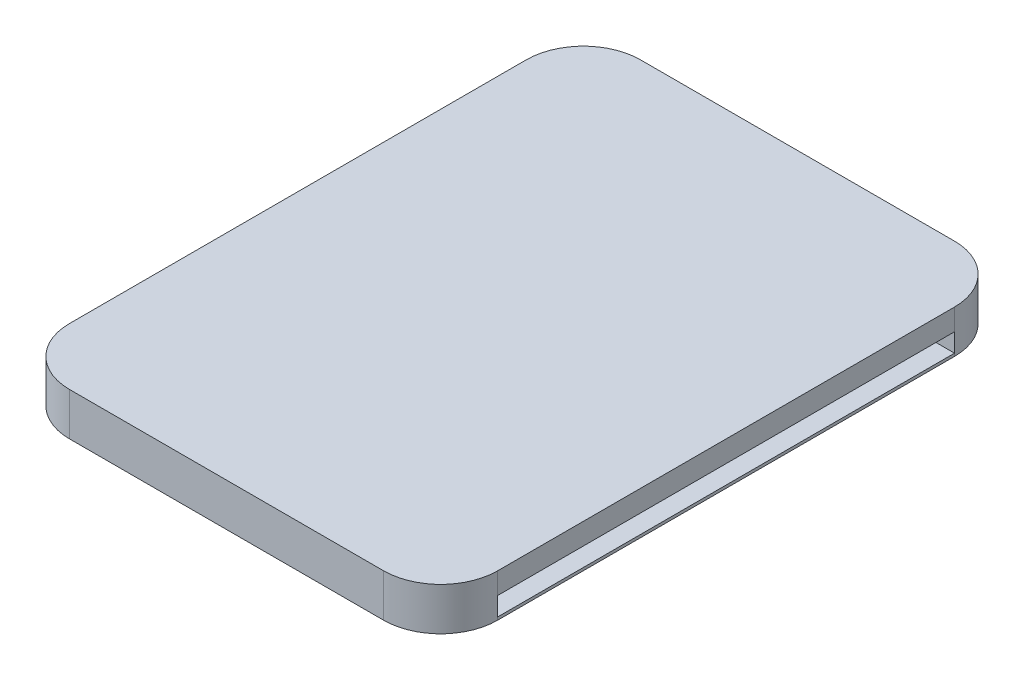
from build123d import *

# Parameters (mm, degrees)
BOSS_EXTRUDE1_DEPTH     = 150
SKETCH2_W               = 400
SKETCH2_H               = 65
CUT_EXTRUDE1_DEPTH      = 1
CUT_EXTRUDE1_DEPTH_BACK = 1501
SKETCH3_W               = 600
SKETCH3_H               = 65
CUT_EXTRUDE2_DEPTH      = 130
SKETCH4_R               = 5
BOSS_EXTRUDE2_DEPTH     = 150
SKETCH6_W               = 55
SKETCH6_H               = 60
CUT_EXTRUDE4_DEPTH      = 200
CUT_EXTRUDE5_DEPTH      = 130
SKETCH8_W               = 1230
SKETCH8_H               = 55
CUT_EXTRUDE6_DEPTH      = 600
SKETCH9_W               = 180
SKETCH9_H               = 135
CUT_EXTRUDE7_DEPTH      = 120


with BuildPart() as part:
    # Sketch1 → Boss-Extrude1 (new body)
    with BuildSketch(Plane(origin=(0, 0, 0), x_dir=(1, 0, 0), z_dir=(0, 1, 0))):
        with BuildLine():
            Line((-550, 1000), (-225, 1000))
            Line((-225, 1000), (225, 1000))
            Line((225, 1000), (550, 1000))
            ThreePointArc((550, 1000), (691.421356237, 941.421356237), (750, 800))
            Line((750, 800), (750, -800))
            ThreePointArc((750, -800), (691.421356237, -941.421356237), (550, -1000))
            Line((550, -1000), (-550, -1000))
            ThreePointArc((-550, -1000), (-691.421356237, -941.421356237), (-750, -800))
            Line((-750, -800), (-750, 800))
            ThreePointArc((-750, 800), (-691.421356237, 941.421356237), (-550, 1000))
        make_face()
    extrude(amount=BOSS_EXTRUDE1_DEPTH)

    # Sketch2 → Cut-Extrude1 (cut, two sides)
    with BuildSketch(Plane(origin=(750, 0, 0), x_dir=(0, 0, -1), z_dir=(1, 0, 0))) as cut_extrude1_sk:
        with Locations((0, 42.5)):
            Rectangle(SKETCH2_W, SKETCH2_H)
    extrude(amount=CUT_EXTRUDE1_DEPTH, mode=Mode.SUBTRACT)
    extrude(cut_extrude1_sk.sketch, amount=-CUT_EXTRUDE1_DEPTH_BACK, mode=Mode.SUBTRACT)

    # Sketch3 → Cut-Extrude2 (cut)
    with BuildSketch(Plane(origin=(750, 0, 0), x_dir=(0, 0, -1), z_dir=(1, 0, 0))):
        with Locations((500, 42.5)):
            Rectangle(SKETCH3_W, SKETCH3_H)
        with Locations((-500, 42.5)):
            Rectangle(SKETCH3_W, SKETCH3_H)
    cut_extrude2 = extrude(amount=-CUT_EXTRUDE2_DEPTH, mode=Mode.SUBTRACT)

    # Mirror1: Cut-Extrude2 across plane
    add(cut_extrude2.mirror(Plane(origin=(0, 0, 0), x_dir=(0, 0, 1), z_dir=(1, 0, 0))), mode=Mode.SUBTRACT)

    # Sketch4 → Boss-Extrude2 (add)
    with BuildSketch(Plane(origin=(0, 150, 0), x_dir=(1, 0, 0), z_dir=(0, 1, 0))):
        with Locations((-670, 100)):
            Circle(SKETCH4_R)
        with Locations((-670, -100)):
            Circle(SKETCH4_R)
    boss_extrude2 = extrude(amount=-BOSS_EXTRUDE2_DEPTH)

    # Mirror2: Boss-Extrude2 across plane
    add(boss_extrude2.mirror(Plane(origin=(0, 0, 0), x_dir=(0, 0, 1), z_dir=(1, 0, 0))))

    # Sketch6 → Cut-Extrude4 (cut)
    with BuildSketch(Plane(origin=(0, 0, -1000), x_dir=(-1, 0, 0), z_dir=(0, 0, -1))):
        with Locations((-350, 75)):
            Rectangle(SKETCH6_W, SKETCH6_H)
        with Locations((350, 75)):
            Rectangle(SKETCH6_W, SKETCH6_H)
    extrude(amount=-CUT_EXTRUDE4_DEPTH, mode=Mode.SUBTRACT)

    # Sketch7 → Cut-Extrude5 (cut)
    with BuildSketch(Plane.XZ):
        with BuildLine():
            Line((385, 480), (385, 600))
            ThreePointArc((385, 600), (350, 635), (315, 600))
            Line((315, 600), (315, 480))
            ThreePointArc((315, 480), (350, 445), (385, 480))
        make_face()
        with BuildLine():
            Line((-315, 480), (-315, 600))
            ThreePointArc((-315, 600), (-350, 635), (-385, 600))
            Line((-385, 600), (-385, 480))
            ThreePointArc((-385, 480), (-350, 445), (-315, 480))
        make_face()
    extrude(amount=-CUT_EXTRUDE5_DEPTH, mode=Mode.SUBTRACT)

    # Sketch8 → Cut-Extrude6 (cut)
    with BuildSketch(Plane(origin=(0, 0, 200), x_dir=(-1, 0, 0), z_dir=(0, 0, -1))):
        with Locations((0, 42.5)):
            Rectangle(SKETCH8_W, SKETCH8_H)
    extrude(amount=-CUT_EXTRUDE6_DEPTH, mode=Mode.SUBTRACT)

    # Sketch9 → Cut-Extrude7 (cut)
    with BuildSketch(Plane(origin=(0, 0, -1000), x_dir=(-1, 0, 0), z_dir=(0, 0, -1))):
        with Locations((-350, 75)):
            Rectangle(SKETCH9_W, SKETCH9_H)
        with Locations((350, 75)):
            Rectangle(SKETCH9_W, SKETCH9_H)
    extrude(amount=-CUT_EXTRUDE7_DEPTH, mode=Mode.SUBTRACT)


solid = part.part
